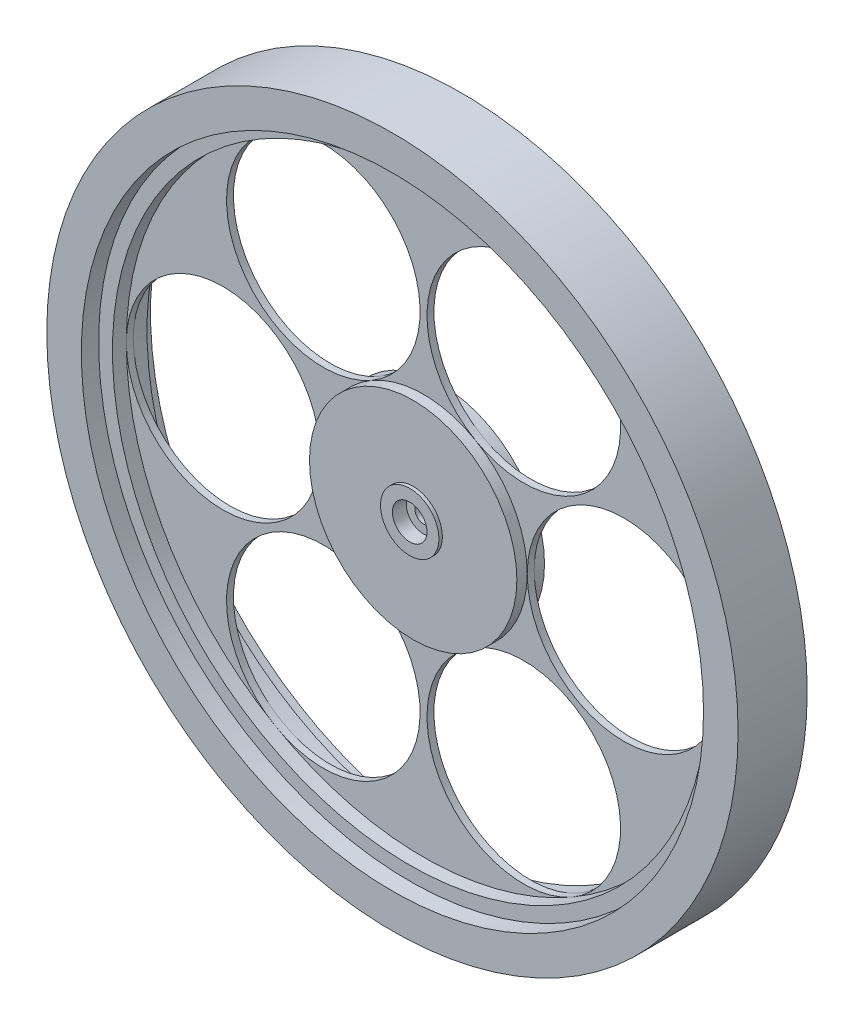
from build123d import *

# Parameters (mm, degrees)
SKETCH1_R             = 3.175
SKETCH1_R_2           = 1.5875
BOSS_EXTRUDE1_DEPTH   = 0.635
BOSS_EXTRUDE1_2_DEPTH = 0.635
BOSS_EXTRUDE1_3_DEPTH = 0.635
BOSS_EXTRUDE1_4_DEPTH = 0.635
BOSS_EXTRUDE1_5_DEPTH = 0.635
BOSS_EXTRUDE1_6_DEPTH = 0.635
BOSS_EXTRUDE1_7_DEPTH = 0.635
SKETCH1_3_R           = 57.15
SKETCH1_3_R_2         = 54.61
SKETCH1_3_R_3         = 5.363953164
SKETCH1_3_R_4         = 3.175
BOSS_EXTRUDE2_DEPTH   = 3.175
SKETCH1_4_R           = 5.363953164
BOSS_EXTRUDE4_DEPTH   = 2.54
SKETCH1_5_R           = 63.5
SKETCH1_5_R_2         = 57.15
BOSS_EXTRUDE5_DEPTH   = 6.35


with BuildPart() as part:
    # Sketch1 → Boss-Extrude1 (new, symmetric)
    with BuildSketch(Plane.XY):
        Circle(SKETCH1_R)
        Circle(SKETCH1_R_2, mode=Mode.SUBTRACT)
    extrude(amount=BOSS_EXTRUDE1_DEPTH, both=True)



with BuildPart() as body_2:
    # Sketch1 → Boss-Extrude1 2 (new, symmetric)
    with BuildSketch(Plane.XY):
        with BuildLine():
            ThreePointArc((54.61, 0), (36.83, -17.78), (19.05, 0))
            ThreePointArc((19.05, 0), (16.497783962, -9.524999965), (9.525000069, -16.497783902))
            ThreePointArc((9.525000069, -16.497783902), (33.812931696, -23.005715651), (27.30500001, -47.293647295))
            ThreePointArc((27.30500001, -47.293647295), (47.293647304, -27.304999995), (54.61, 0))
        make_face()
    extrude(amount=BOSS_EXTRUDE1_2_DEPTH, both=True)


with BuildPart() as body_3:
    # Sketch1 → Boss-Extrude1 3 (new, symmetric)
    with BuildSketch(Plane.XY):
        with BuildLine():
            ThreePointArc((9.524999881, 16.497784011), (16.497783908, 9.525000059), (19.05, 0))
            ThreePointArc((19.05, 0), (36.83, 17.78), (54.61, 0))
            ThreePointArc((54.61, 0), (47.293647334, 27.304999942), (27.305000115, 47.293647234))
            ThreePointArc((27.305000115, 47.293647234), (33.812931612, 23.005715504), (9.524999881, 16.497784011))
        make_face()
    extrude(amount=BOSS_EXTRUDE1_3_DEPTH, both=True)


with BuildPart() as body_4:
    # Sketch1 → Boss-Extrude1 4 (new, symmetric)
    with BuildSketch(Plane.XY):
        with BuildLine():
            ThreePointArc((-9.524999997, 16.497783944), (-6.7e-08, 19.05), (9.524999881, 16.497784011))
            ThreePointArc((9.524999881, 16.497784011), (3.017068388, 40.785715738), (27.305000115, 47.293647234))
            ThreePointArc((27.305000115, 47.293647234), (3.56e-07, 54.61), (-27.304999499, 47.29364759))
            ThreePointArc((-27.304999499, 47.29364759), (-3.017068177, 40.785715372), (-9.524999997, 16.497783944))
        make_face()
    extrude(amount=BOSS_EXTRUDE1_4_DEPTH, both=True)


with BuildPart() as body_5:
    # Sketch1 → Boss-Extrude1 5 (new, symmetric)
    with BuildSketch(Plane.XY):
        with BuildLine():
            ThreePointArc((27.30500001, -47.293647295), (3.017068304, -40.785715592), (9.525000069, -16.497783902))
            ThreePointArc((9.525000069, -16.497783902), (-3.12e-07, -19.05), (-9.525000609, -16.497783591))
            ThreePointArc((-9.525000609, -16.497783591), (-3.017068222, -40.785715451), (-27.305000268, -47.293647146))
            ThreePointArc((-27.305000268, -47.293647146), (-1.49e-07, -54.61), (27.30500001, -47.293647295))
        make_face()
    extrude(amount=BOSS_EXTRUDE1_5_DEPTH, both=True)


with BuildPart() as body_6:
    # Sketch1 → Boss-Extrude1 6 (new, symmetric)
    with BuildSketch(Plane.XY):
        with BuildLine():
            ThreePointArc((-19.05, 0), (-16.497783941, 9.525000001), (-9.524999997, 16.497783944))
            ThreePointArc((-9.524999997, 16.497783944), (-33.812931823, 23.005715871), (-27.304999499, 47.29364759))
            ThreePointArc((-27.304999499, 47.29364759), (-47.293647156, 27.305000251), (-54.61, 0))
            ThreePointArc((-54.61, 0), (-36.83, 17.78), (-19.05, 0))
        make_face()
    extrude(amount=BOSS_EXTRUDE1_6_DEPTH, both=True)


with BuildPart() as body_7:
    # Sketch1 → Boss-Extrude1 7 (new, symmetric)
    with BuildSketch(Plane.XY):
        with BuildLine():
            ThreePointArc((-27.305000268, -47.293647146), (-33.812931778, -23.005715792), (-9.525000609, -16.497783591))
            ThreePointArc((-9.525000609, -16.497783591), (-16.497784118, -9.524999696), (-19.05, 0))
            ThreePointArc((-19.05, 0), (-36.83, -17.78), (-54.61, 0))
            ThreePointArc((-54.61, 0), (-47.293647378, -27.304999866), (-27.305000268, -47.293647146))
        make_face()
    extrude(amount=BOSS_EXTRUDE1_7_DEPTH, both=True)


with BuildPart() as part_1:
    add(part.part)

    add(body_4.part)  # Boss-Extrude2 merges body 4

    add(body_7.part)  # Boss-Extrude2 merges body 7

    add(body_2.part)  # Boss-Extrude2 merges body 2
    # Sketch1_3 → Boss-Extrude2 (add, symmetric)
    # profile 1 of 2: a face of its own
    with BuildSketch(Plane.XY):
        Circle(SKETCH1_3_R)
        Circle(SKETCH1_3_R_2, mode=Mode.SUBTRACT)
    # profile 2 of 2: a face of its own
    with BuildSketch(Plane.XY):
        Circle(SKETCH1_3_R_3)
        Circle(SKETCH1_3_R_4, mode=Mode.SUBTRACT)
    extrude(amount=BOSS_EXTRUDE2_DEPTH, both=True)


    add(body_3.part)  # Boss-Extrude4 merges body 3

    add(body_5.part)  # Boss-Extrude4 merges body 5

    add(body_6.part)  # Boss-Extrude4 merges body 6
    # Sketch1_4 → Boss-Extrude4 (add, symmetric)
    with BuildSketch(Plane.XY):
        with BuildLine():
            ThreePointArc((9.525000069, -16.497783902), (16.497783962, -9.524999965), (19.05, 0))
            ThreePointArc((19.05, 0), (16.497783908, 9.525000059), (9.524999881, 16.497784011))
            ThreePointArc((9.524999881, 16.497784011), (-6.7e-08, 19.05), (-9.524999997, 16.497783944))
            ThreePointArc((-9.524999997, 16.497783944), (-16.497783941, 9.525000001), (-19.05, 0))
            ThreePointArc((-19.05, 0), (-16.497784118, -9.524999696), (-9.525000609, -16.497783591))
            ThreePointArc((-9.525000609, -16.497783591), (-3.12e-07, -19.05), (9.525000069, -16.497783902))
        make_face()
        Circle(SKETCH1_4_R, mode=Mode.SUBTRACT)
    extrude(amount=BOSS_EXTRUDE4_DEPTH, both=True)

    # Sketch1_5 → Boss-Extrude5 (add, symmetric)
    with BuildSketch(Plane.XY):
        Circle(SKETCH1_5_R)
        Circle(SKETCH1_5_R_2, mode=Mode.SUBTRACT)
    extrude(amount=BOSS_EXTRUDE5_DEPTH, both=True)


solid = part_1.part
